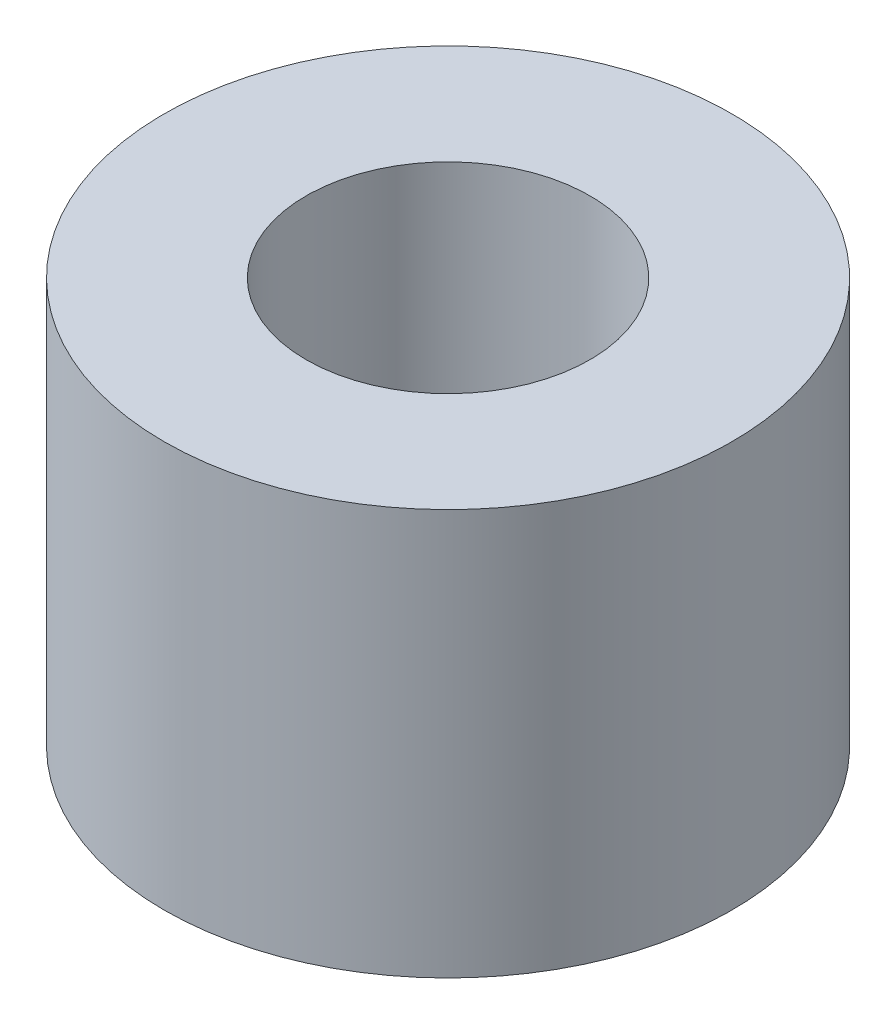
from build123d import *

# Parameters (mm, degrees)
SKETCH1_R           = 3.5
SKETCH1_R_2         = 1.75
BOSS_EXTRUDE1_DEPTH = 5


with BuildPart() as part:
    # Sketch1 → Boss-Extrude1 (new body)
    with BuildSketch(Plane(origin=(0, 0, 0), x_dir=(1, 0, 0), z_dir=(0, 1, 0))):
        Circle(SKETCH1_R)
        Circle(SKETCH1_R_2, mode=Mode.SUBTRACT)
    extrude(amount=BOSS_EXTRUDE1_DEPTH)


solid = part.part
